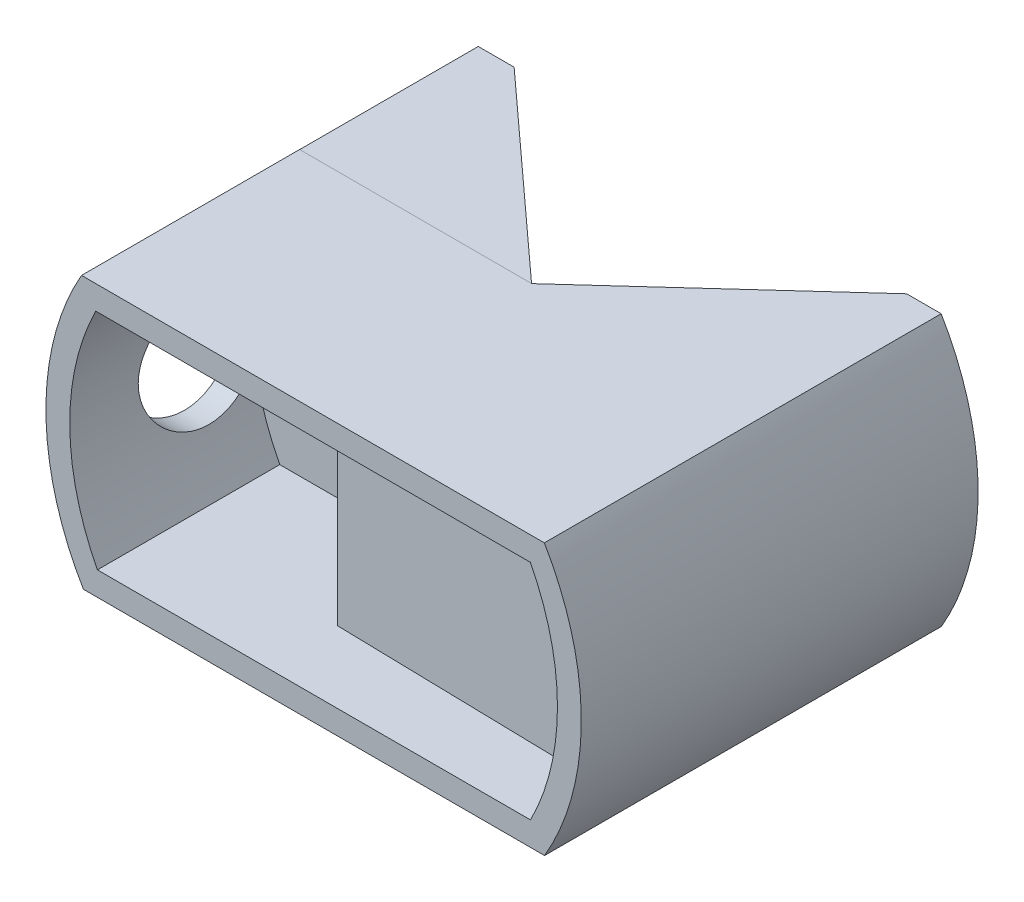
from build123d import *

# Parameters (mm, degrees)
BOSS_EXTRUDE1_DEPTH     = 15.295
CUT_EXTRUDE1_DEPTH      = 206.919868261
FLOOR_START             = 3
FLOOR_2_DEPTH           = 3
BOSS_EXTRUDE4_START     = 9.785
BOSS_EXTRUDE4_DEPTH     = 9.785
CUT_EXTRUDE3_REACH      = 207.92
CUT_EXTRUDE3_END_RADIUS = 20.596434206
SKETCH7_R               = 5.25
BOSS_EXTRUDE5_REACH     = 176.665
SKETCH14_OUTSIDE_W      = 59.009
SKETCH14_OUTSIDE_H      = 36.805
CUT_EXTRUDE4_DEPTH      = 33.295


with BuildPart() as part:
    # Sketch1 → Boss-Extrude1 (new body)
    with BuildSketch(Plane(origin=(0, 0, -12.295), x_dir=(-1, 0, 0), z_dir=(0, 0, -1))):
        with BuildLine():
            Line((-169.369133898, -111.490025098), (-130.678433581, -111.48937301))
            ThreePointArc((-130.678433581, -111.48937301), (-127.534095849, -100.145401406), (-130.522109497, -88.759255177))
            Line((-130.522109497, -88.759255177), (-169.350721063, -88.778648203))
            ThreePointArc((-169.350721063, -88.778648203), (-172.450070697, -100.131831373), (-169.369133898, -111.490025098))
        make_face()
    extrude(amount=-BOSS_EXTRUDE1_DEPTH)

    # Sketch2 → Cut-Extrude1 (cut, through all)
    with BuildSketch(Plane.XY.offset(3)):
        with BuildLine():
            Line((168.171133654, -90.778059306), (131.717568579, -90.759852501))
            ThreePointArc((131.717568579, -90.759852501), (129.534116109, -100.141151153), (131.855022492, -109.48939284))
            Line((131.855022492, -109.48939284), (168.187605365, -109.490005184))
            ThreePointArc((168.187605365, -109.490005184), (170.450070154, -100.132033398), (168.171133654, -90.778059306))
        make_face()
    extrude(amount=-CUT_EXTRUDE1_DEPTH, mode=Mode.SUBTRACT)

    # Sketch4 → floor 2 (add)
    with BuildSketch(Plane(origin=(0, 0, -12.295), x_dir=(-1, 0, 0), z_dir=(0, 0, -1)).offset(FLOOR_START)):
        with BuildLine():
            Line((-169.369133898, -111.490025098), (-130.678433581, -111.48937301))
            ThreePointArc((-130.678433581, -111.48937301), (-127.534095849, -100.145401406), (-130.522109497, -88.759255177))
            Line((-130.522109497, -88.759255177), (-169.350721063, -88.778648203))
            ThreePointArc((-169.350721063, -88.778648203), (-172.450070697, -100.131831373), (-169.369133898, -111.490025098))
        make_face()
    extrude(amount=-FLOOR_2_DEPTH)

    # Sketch6 → Boss-Extrude4 (add)
    with BuildSketch(Plane.XY.offset(-12.295).offset(BOSS_EXTRUDE4_START)):
        with BuildLine():
            Line((146.5, -90.767235615), (146.5, -108.989639664))
            Line((146.5, -108.989639664), (168.187605365, -109.490005184))
            ThreePointArc((168.187605365, -109.490005184), (170.450070154, -100.132033398), (168.171133654, -90.778059306))
            Line((168.171133654, -90.778059306), (146.5, -90.767235615))
        make_face()
    extrude(amount=-BOSS_EXTRUDE4_DEPTH)

    # Cut-Extrude3: up to this cylinder (the profile starts outside it)
    cut_extrude3_end = Plane(origin=(150.129995683, -99.990000393, -7.995), z_dir=(0, 0, 1)) * Cylinder(CUT_EXTRUDE3_END_RADIUS, 458.032868411, mode=Mode.PRIVATE)
    # Sketch7 → Cut-Extrude3 (cut, up to the surface)
    with BuildSketch(Plane(origin=(0, 0, 0), x_dir=(0, 0, -1), z_dir=(1, 0, 0)), mode=Mode.PRIVATE) as cut_extrude3_sk1:
        with Locations(Location((7.995, -100, 0), (0, 0, 180))):
            Circle(SKETCH7_R)
    cut_extrude3_tool1 = extrude(cut_extrude3_sk1.sketch, amount=CUT_EXTRUDE3_REACH, mode=Mode.PRIVATE) - cut_extrude3_end
    add(cut_extrude3_tool1.solids().sort_by_distance((0, -100, -7.995))[0], mode=Mode.SUBTRACT)

    # Boss-Extrude5: up to this face of the body (flat: up to its plane)
    boss_extrude5_end = Plane(part.part.faces().sort_by_distance((150.023783739, -111.489699054, -6.1475))[0])
    # Sketch11 → Boss-Extrude5 (add, up to the picked face)
    with BuildSketch(Plane(origin=(-0.044298414, -88.694043528, 0), x_dir=(0.9999998752738909, -0.0004994519023308322, 0), z_dir=(0.0004994519023308322, 0.9999998752738909, 0)), mode=Mode.PRIVATE) as boss_extrude5_sk1:
        Polygon((150.03815576, 15.295), (166.500079456, 30.295), (172.500079456, 30.295), (172.500079456, 15.295), align=None)
    boss_extrude5_tool1 = split(extrude(boss_extrude5_sk1.sketch, amount=-BOSS_EXTRUDE5_REACH, mode=Mode.PRIVATE), bisect_by=boss_extrude5_end, keep=Keep.BOTH, mode=Mode.PRIVATE)
    boss_extrude5 = boss_extrude5_tool1.solids().sort_by(Axis((164.546837, -88.776249, -21.34904), (-0.0004994519023308322, -0.9999998752738909, 0)))[0]
    add(boss_extrude5)

    # Mirror1: Boss-Extrude5 across plane
    add(boss_extrude5.mirror(Plane(origin=(149.98984246, -0.002527909, 0), x_dir=(0, 0, 1), z_dir=(-0.9999999998579736, 1.6853871084051315e-05, 0))))

    # Sketch14 outside → Cut-Extrude4 (cut)
    with BuildSketch(Plane.XY.offset(3)):
        with Locations((149.9885, -100.1245)):
            Rectangle(SKETCH14_OUTSIDE_W, SKETCH14_OUTSIDE_H)
        with BuildLine():
            Line((169.350721063, -88.778648203), (130.522109497, -88.759255177))
            ThreePointArc((130.522109497, -88.759255177), (127.534095849, -100.145401406), (130.678433581, -111.48937301))
            Line((130.678433581, -111.48937301), (169.369133898, -111.490025098))
            ThreePointArc((169.369133898, -111.490025098), (172.450070697, -100.131831373), (169.350721063, -88.778648203))
        make_face(mode=Mode.SUBTRACT)
    extrude(amount=-CUT_EXTRUDE4_DEPTH, mode=Mode.SUBTRACT)


solid = part.part
